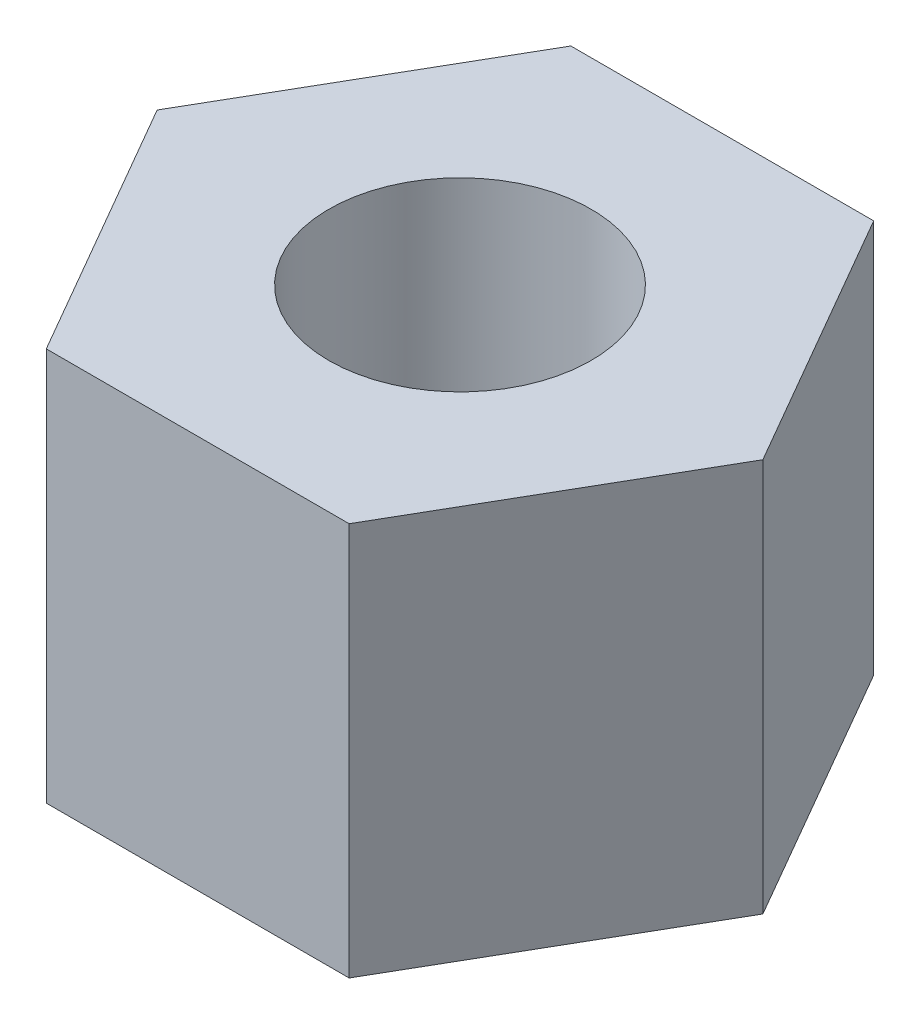
from build123d import *

# Parameters (mm, degrees)
SKETCH_1_R      = 1
EXTRUDE_1_DEPTH = 3


with BuildPart() as part:
    # 草图1 → 凸台-拉伸1 (new body)
    with BuildSketch(Plane(origin=(0, 0, 0), x_dir=(1, 0, 0), z_dir=(0, 1, 0))):
        Polygon((2.309401077, 0), (1.154700538, 2), (-1.154700538, 2), (-2.309401077, 0), (-1.154700538, -2), (1.154700538, -2), align=None)
        Circle(SKETCH_1_R, mode=Mode.SUBTRACT)
    extrude(amount=EXTRUDE_1_DEPTH)


solid = part.part
